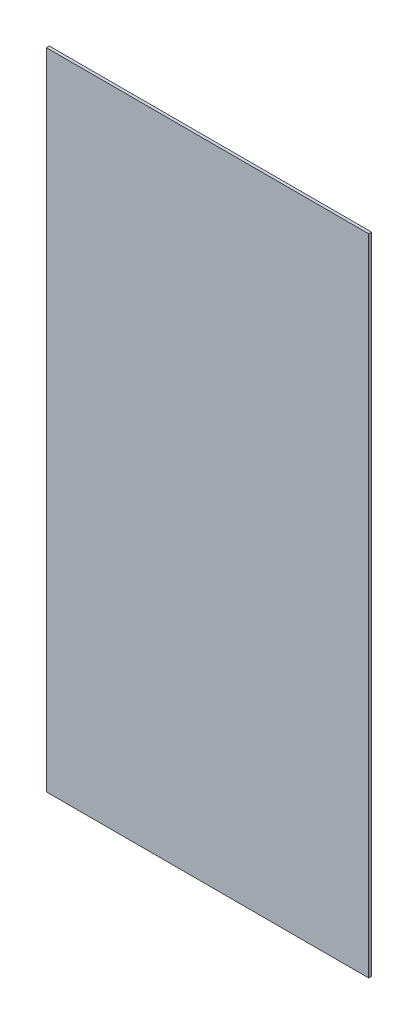
from build123d import *

# Parameters (mm, degrees)
SKETCH1_W           = 1219.2
SKETCH1_H           = 2438.4
BOSS_EXTRUDE1_DEPTH = 11.1125


with BuildPart() as part:
    # Sketch1 → Boss-Extrude1 (new body)
    with BuildSketch(Plane.XY):
        with Locations((609.6, 1219.2)):
            Rectangle(SKETCH1_W, SKETCH1_H)
    extrude(amount=BOSS_EXTRUDE1_DEPTH)


solid = part.part
